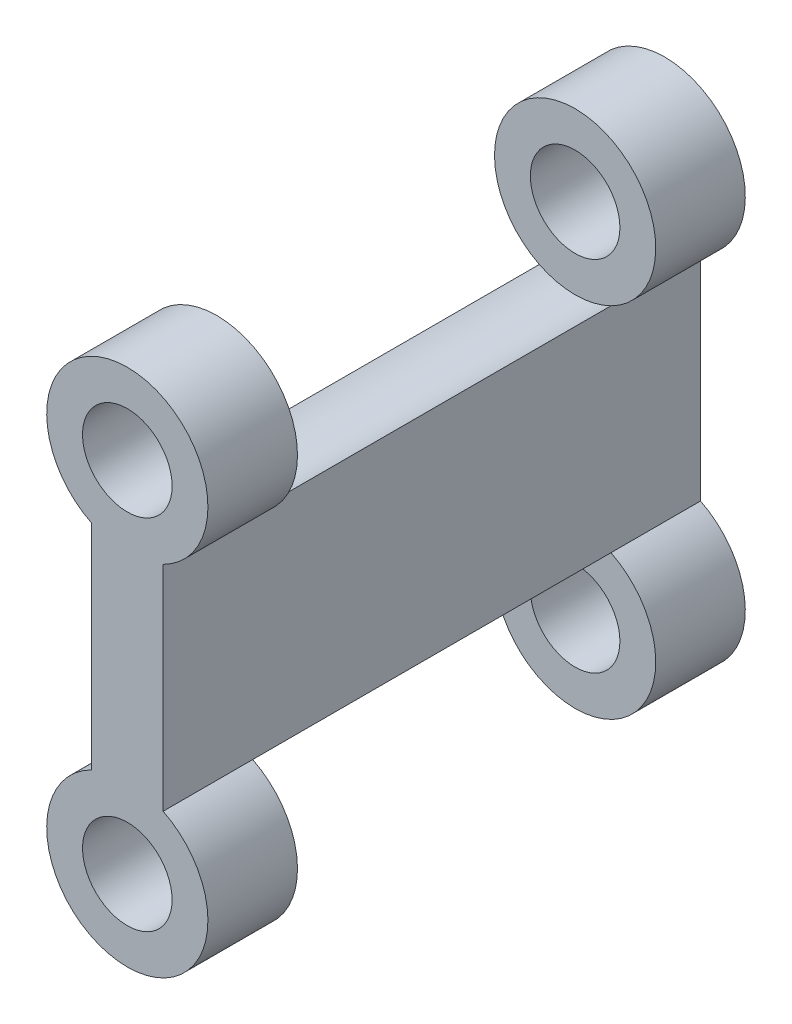
from build123d import *

# Parameters (mm, degrees)
SKETCH1_R           = 3.175
BOSS_EXTRUDE1_DEPTH = 19.05
SKETCH1_3_R         = 5.715
SKETCH1_3_R_2       = 3.175
CUT_EXTRUDE2_DEPTH  = 12.7


with BuildPart() as part:
    # Sketch1 → Boss-Extrude1 (new, symmetric)
    with BuildSketch(Plane.XY):
        with BuildLine():
            Line((-2.54, 20.28046633), (-2.54, 5.11953367))
            ThreePointArc((-2.54, 5.11953367), (0, -5.715), (2.54, 5.11953367))
            Line((2.54, 5.11953367), (2.54, 20.28046633))
            ThreePointArc((2.54, 20.28046633), (0, 31.115), (-2.54, 20.28046633))
        make_face()
        with Locations((0, 25.4)):
            Circle(SKETCH1_R, mode=Mode.SUBTRACT)
        Circle(SKETCH1_R, mode=Mode.SUBTRACT)
    extrude(amount=BOSS_EXTRUDE1_DEPTH, both=True)

    # Sketch1_3 → Cut-Extrude2 (cut, symmetric)
    # profile 1 of 2: a face of its own
    with BuildSketch(Plane.XY):
        with Locations((0, 25.4)):
            Circle(SKETCH1_3_R)
        with Locations((0, 25.4)):
            Circle(SKETCH1_3_R_2, mode=Mode.SUBTRACT)
    # profile 2 of 2: a face of its own
    with BuildSketch(Plane.XY):
        Circle(SKETCH1_3_R)
        Circle(SKETCH1_3_R_2, mode=Mode.SUBTRACT)
    extrude(amount=CUT_EXTRUDE2_DEPTH, both=True, mode=Mode.SUBTRACT)


solid = part.part
